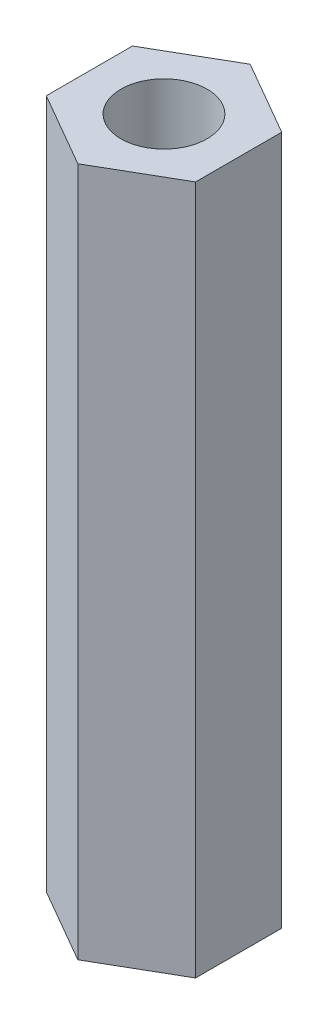
from build123d import *

# Parameters (mm, degrees)
ESQUISSE1_R      = 2.5
EXTRUSION1_DEPTH = 40


with BuildPart() as part:
    # Esquisse1 → Extrusion1 (new body)
    with BuildSketch(Plane(origin=(0, 0, 0), x_dir=(1, 0, 0), z_dir=(0, 1, 0))):
        Polygon((0, 5), (-4.330127019, 2.5), (-4.330127019, -2.5), (0, -5), (4.330127019, -2.5), (4.330127019, 2.5), align=None)
        Circle(ESQUISSE1_R, mode=Mode.SUBTRACT)
    extrude(amount=EXTRUSION1_DEPTH)


solid = part.part
